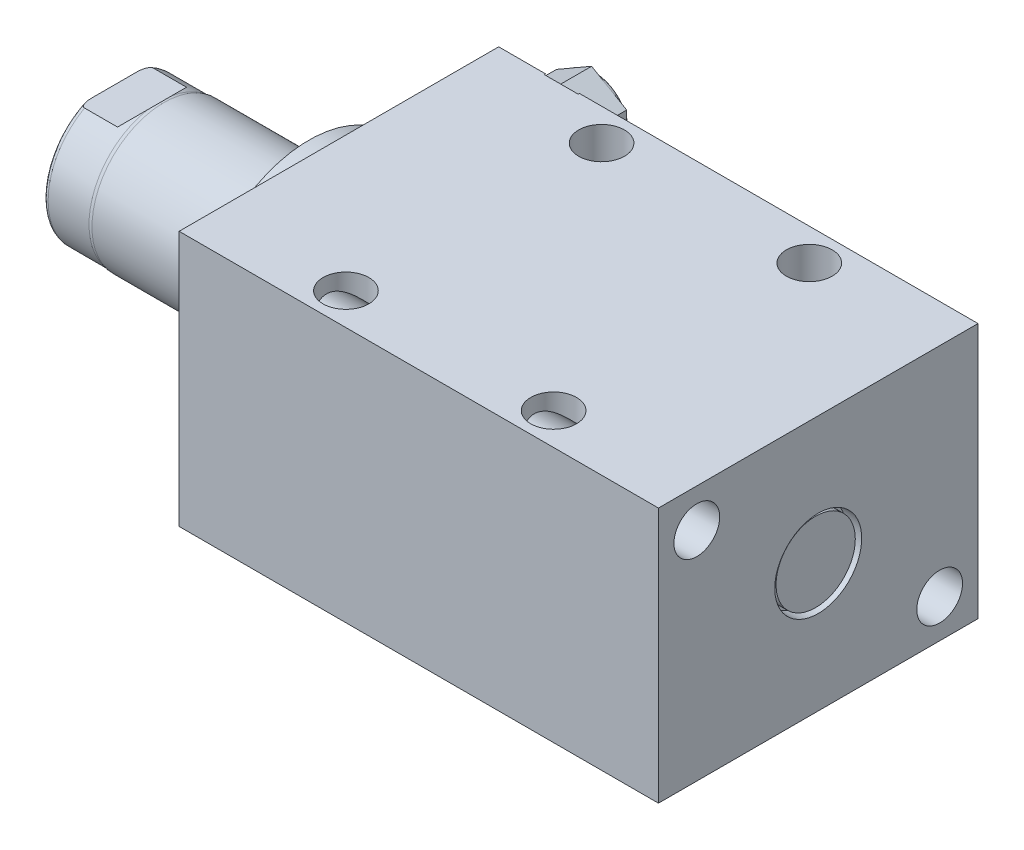
from build123d import *

# Parameters (mm, degrees)
SKETCH1_W            = 63.5
SKETCH1_H            = 50.8
EXTRUDE1_DEPTH       = 95.25
LPATTERN1_COUNT      = 2
LPATTERN1_PITCH      = 69.85
LPATTERN1_COUNT_DIR2 = 2
LPATTERN1_PITCH_DIR2 = 17.45
SKETCH5_R            = 22.225
EXTRUDE2_DEPTH       = 5.969
SKETCH6_W            = 14.2748
SKETCH6_H            = 38.735
CUT_EXTRUDE4_DEPTH   = 30.48
HOLE1_D              = 9.093
HOLE1_DEPTH          = 95.25
HOLE2_D              = 9.093
HOLE2_DEPTH          = 50.8
EXTRUDE3_DEPTH       = 6.78
SKETCH21_R           = 7.874
EXTRUDE4_DEPTH       = 2.54
LPATTERN2_COUNT      = 2
LPATTERN2_PITCH      = 41.275


with BuildPart() as part:
    # Sketch1 → Extrude1 (new body)
    with BuildSketch(Plane(origin=(0, 0, 0), x_dir=(0, 0, -1), z_dir=(1, 0, 0))):
        Rectangle(SKETCH1_W, SKETCH1_H)
    extrude(amount=EXTRUDE1_DEPTH)

    # S2D0002 → Cut-Revolve1 (revolve, cut)
    with BuildSketch(Plane(origin=(0, 17.45, 0), x_dir=(-1, 0, 0), z_dir=(0, 1, 0)), mode=Mode.PRIVATE) as cut_revolve1_sk:
        Polygon((-17.7165, -31.496), (-21.336, -31.496), (-21.336, -31.75), (-12.7, -31.75), (-12.7, -18.034), (-17.1196, -18.034), (-17.1196, -30.8737), (-17.7165, -31.4706), align=None)
    cut_revolve1 = revolve(cut_revolve1_sk.sketch.rotate(Axis((12.7, 17.45, -19.13842003), (0, 0, 1)), 180), axis=Axis((12.7, 17.45, -19.13842003), (0, 0, 1)), mode=Mode.SUBTRACT)  # turned: the seam where the file's is

    # LPattern1: Cut-Revolve1 2 × 2, 2 skipped
    with Locations(*[(i * LPATTERN1_PITCH, -j * LPATTERN1_PITCH_DIR2, 0) for i in range(LPATTERN1_COUNT) for j in range(LPATTERN1_COUNT_DIR2) if (i, j) not in ((0, 0), (0, 1), (1, 0))]):
        add(cut_revolve1, mode=Mode.SUBTRACT)

    # Sketch5 → Extrude2 (add)
    with BuildSketch(Plane.ZY):
        Circle(SKETCH5_R)
    extrude(amount=EXTRUDE2_DEPTH)

    # Sketch6 → Revolve1 (revolve)
    with BuildSketch(Plane(origin=(0, 0, 0), x_dir=(0, 0, 1), z_dir=(0, -1, 0)), mode=Mode.PRIVATE) as revolve1_sk:
        with Locations((-7.1374, 25.3365)):
            Rectangle(SKETCH6_W, SKETCH6_H)
    revolve(revolve1_sk.sketch.rotate(Axis((5.754582971, 0, 0), (-1, 0, 0)), 180), axis=Axis((5.754582971, 0, 0), (-1, 0, 0)))  # turned: the seam where the file's is

    # S2D0001 → Cut-Revolve4 (revolve, cut)
    with BuildSketch(Plane(origin=(-18.511260017, 3.2639, 0), x_dir=(0, 1, 0), z_dir=(0, 0, 1)), mode=Mode.PRIVATE) as cut_revolve4_sk:
        Polygon((1.8671, 24.081370048), (1.8671, 9.352739983), (-3.2639, 9.352739983), (-3.2639, 26.192739983), (3.0861, 26.192739983), align=None)
    revolve(cut_revolve4_sk.sketch.rotate(Axis((0, 0, 0), (-1, 0, 0)), 90), axis=Axis((0, 0, 0), (-1, 0, 0)), mode=Mode.SUBTRACT)  # turned: the seam where the file's is

    # Sketch8 → Cut-Revolve5 (revolve, cut)
    with BuildSketch(Plane(origin=(0, 0, 0), x_dir=(0, 0, -1), z_dir=(0, 1, 0)), mode=Mode.PRIVATE) as cut_revolve5_sk:
        with BuildLine():
            Line((-14.2748, 34.798), (-14.097, 35.56))
            Line((-14.097, 35.56), (-14.097, 43.688))
            ThreePointArc((-14.097, 43.688), (-13.79942049, 44.40642049), (-13.081, 44.704))
            Line((-13.081, 44.704), (-14.2748, 44.704))
            Line((-14.2748, 44.704), (-14.2748, 34.798))
        make_face()
    revolve(cut_revolve5_sk.sketch.rotate(Axis((-12.65936, 0, 0), (-1, 0, 0)), 180), axis=Axis((-12.65936, 0, 0), (-1, 0, 0)), mode=Mode.SUBTRACT)  # turned: the seam where the file's is

    # Sketch12 → Cut-Extrude4 (cut, symmetric)
    with BuildSketch(Plane(origin=(0, 0, 0), x_dir=(0, -1, 0), z_dir=(0, 0, -1))):
        Polygon((12.319, 44.704), (12.319, 37.135), (14.2748, 35.1792), (14.2748, 44.704), align=None)
        Polygon((-12.319, 44.704), (-12.319, 37.135), (-14.2748, 35.1792), (-14.2748, 44.704), align=None)
    extrude(amount=CUT_EXTRUDE4_DEPTH, both=True, mode=Mode.SUBTRACT)

    # Hole1
    with Locations(Plane.ZY):
        with Locations((-24.13, -17.78), (24.13, 17.78)):
            Hole(HOLE1_D / 2, depth=HOLE1_DEPTH)

    # Hole2
    with Locations(Plane(origin=(0, 25.4, 0), x_dir=(-1, 0, 0), z_dir=(0, 1, 0))):
        with Locations((-26.797, -25.4), (-26.797, 25.4)):
            hole2 = Hole(HOLE2_D / 2, depth=HOLE2_DEPTH)

    # Sketch18 → Extrude3 (add)
    with BuildSketch(Plane(origin=(0, 0, -31.496), x_dir=(-1, 0, 0), z_dir=(0, 0, -1))):
        Polygon((-5.715, 21.48279163), (-12.7, 25.515583261), (-19.685, 21.48279163), (-19.685, 13.41720837), (-12.7, 9.384416739), (-5.715, 13.41720837), align=None)
    extrude(amount=EXTRUDE3_DEPTH)

    # Sketch19 → Cut-Revolve6 (revolve, cut)
    with BuildSketch(Plane(origin=(0, 17.45, 0), x_dir=(-1, 0, 0), z_dir=(0, 1, 0)), mode=Mode.PRIVATE) as cut_revolve6_sk:
        with BuildLine():
            Line((-18.923, -38.276), (-18.923, -40.689))
            Line((-18.923, -40.689), (-22.098, -40.689))
            Line((-22.098, -40.689), (-22.098, -37.514))
            Line((-22.098, -37.514), (-19.685, -37.514))
            ThreePointArc((-19.685, -37.514), (-19.461815367, -38.052815367), (-18.923, -38.276))
        make_face()
    revolve(cut_revolve6_sk.sketch.rotate(Axis((12.7, 17.45, -18.51025594), (0, 0, -1)), 180), axis=Axis((12.7, 17.45, -18.51025594), (0, 0, -1)), mode=Mode.SUBTRACT)  # turned: the seam where the file's is

    # Sketch20 → Cut-Revolve7 (revolve, cut)
    with BuildSketch(Plane(origin=(0, 0, 0), x_dir=(1, 0, 0), z_dir=(0, 1, 0)), mode=Mode.PRIVATE) as cut_revolve7_sk:
        Polygon((95.25, 8.636), (92.202, 8.636), (92.202, 5.0165), (92.1766, 5.0165), (91.5797, 4.4196), (81.6356, 4.4196), (81.6356, 0), (95.25, 0), align=None)
    revolve(cut_revolve7_sk.sketch.rotate(Axis((0, 0, 0), (1, 0, 0)), 180), axis=Axis((0, 0, 0), (1, 0, 0)), mode=Mode.SUBTRACT)  # turned: the seam where the file's is

    # Sketch21 → Extrude4 (add)
    with BuildSketch(Plane(origin=(92.202, 0, 0), x_dir=(0, 0, -1), z_dir=(1, 0, 0))):
        Circle(SKETCH21_R)
    extrude(amount=EXTRUDE4_DEPTH)

    # LPattern2: Hole2 ×2
    with Locations(*[(i * LPATTERN2_PITCH, 0, 0) for i in range(1, LPATTERN2_COUNT)]):
        add(hole2, mode=Mode.SUBTRACT)


solid = part.part
